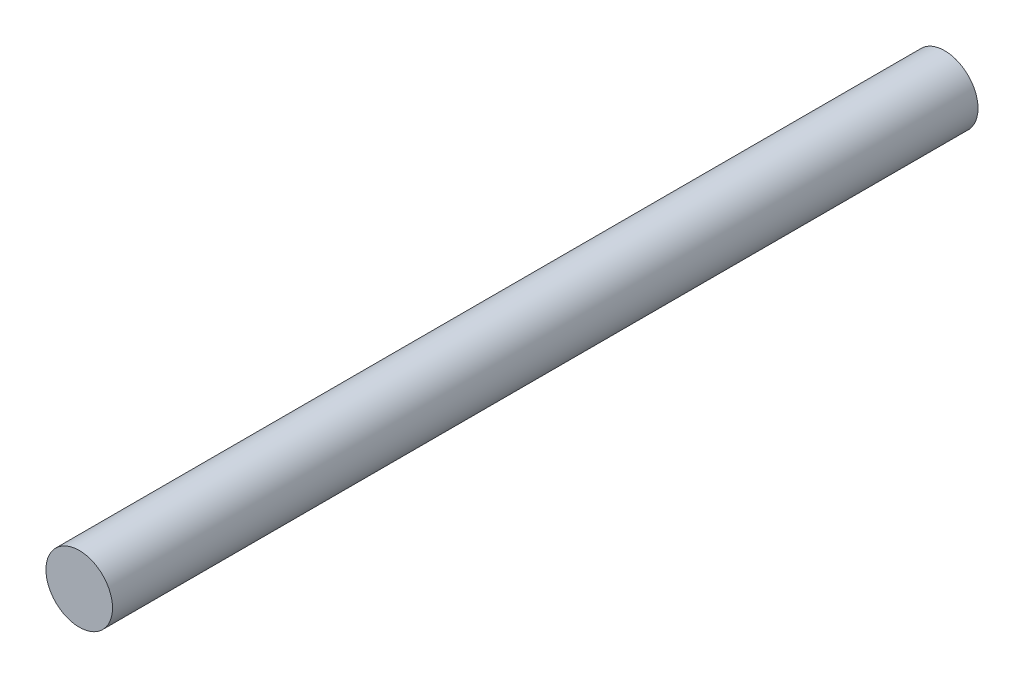
from build123d import *

# Parameters (mm, degrees)
SKETCH1_R           = 6.35
BOSS_EXTRUDE1_DEPTH = 82.55


with BuildPart() as part:
    # Sketch1 → Boss-Extrude1 (new body, symmetric)
    with BuildSketch(Plane.XY):
        Circle(SKETCH1_R)
    extrude(amount=BOSS_EXTRUDE1_DEPTH, both=True)


solid = part.part
